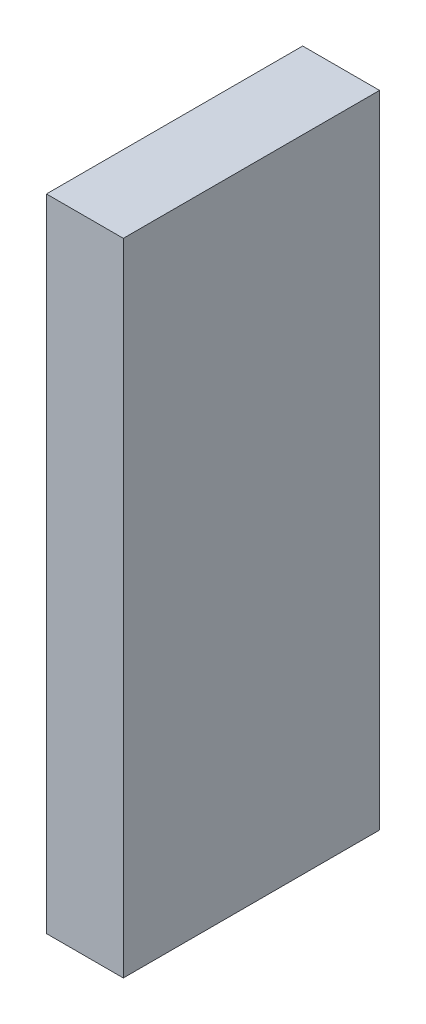
from build123d import *

# Parameters (mm, degrees)
SKETCH1_W           = 3
SKETCH1_H           = 10
BOSS_EXTRUDE1_DEPTH = 25


with BuildPart() as part:
    # Sketch1 → Boss-Extrude1 (new body)
    with BuildSketch(Plane(origin=(0, 0, 0), x_dir=(1, 0, 0), z_dir=(0, 1, 0))):
        with Locations((-8.129716691, -61.188416278)):
            Rectangle(SKETCH1_W, SKETCH1_H)
    extrude(amount=BOSS_EXTRUDE1_DEPTH)


solid = part.part
